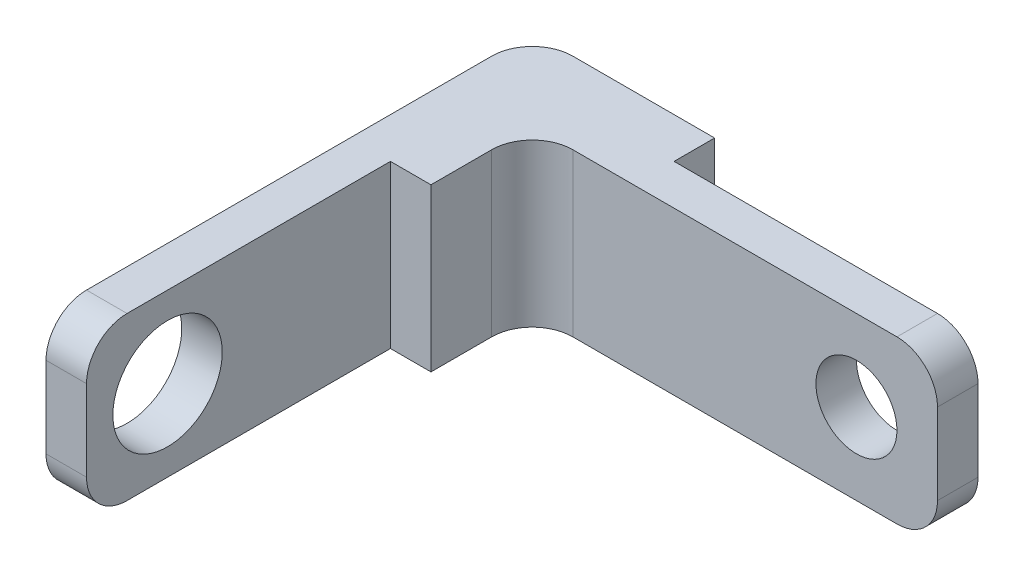
from build123d import *

# Parameters (mm, degrees)
SKETCH2_W           = 120
SKETCH2_H           = 40
BOSS_EXTRUDE1_DEPTH = 20
SKETCH3_W           = 20
SKETCH3_H           = 40
BOSS_EXTRUDE2_DEPTH = 100
SKETCH4_W           = 75
SKETCH4_H           = 40
CUT_EXTRUDE1_DEPTH  = 10
SKETCH5_W           = 75
SKETCH5_H           = 40
CUT_EXTRUDE2_DEPTH  = 10
CUT_EXTRUDE3_REACH  = 12
SKETCH6_R           = 13.5
FILLET2_R           = 10
SKETCH7_R           = 10
CUT_EXTRUDE4_DEPTH  = 10
FILLET3_R           = 10


with BuildPart() as part:
    # Sketch2 → Boss-Extrude1 (new body)
    with BuildSketch(Plane.XY):
        Rectangle(SKETCH2_W, SKETCH2_H)
    extrude(amount=BOSS_EXTRUDE1_DEPTH)

    # Sketch3 → Boss-Extrude2 (add)
    with BuildSketch(Plane.XY.offset(20)):
        with Locations((-50, 0)):
            Rectangle(SKETCH3_W, SKETCH3_H)
    extrude(amount=BOSS_EXTRUDE2_DEPTH)

    # Sketch4 → Cut-Extrude1 (cut)
    with BuildSketch(Plane(origin=(0, 0, 0), x_dir=(-1, 0, 0), z_dir=(0, 0, -1))):
        with Locations((-22.5, 0)):
            Rectangle(SKETCH4_W, SKETCH4_H)
    extrude(amount=-CUT_EXTRUDE1_DEPTH, mode=Mode.SUBTRACT)

    # Sketch5 → Cut-Extrude2 (cut)
    with BuildSketch(Plane(origin=(-40, 0, 0), x_dir=(0, 0, -1), z_dir=(1, 0, 0))):
        with Locations((-82.5, 0)):
            Rectangle(SKETCH5_W, SKETCH5_H)
    extrude(amount=-CUT_EXTRUDE2_DEPTH, mode=Mode.SUBTRACT)

    # Sketch6 → Cut-Extrude3 (cut, up to next)
    with BuildSketch(Plane(origin=(-50, 0, 0), x_dir=(0, 0, -1), z_dir=(1, 0, 0)), mode=Mode.PRIVATE) as cut_extrude3_sk1:
        with Locations((-100, 0)):
            Circle(SKETCH6_R)
    cut_extrude3_tool1 = extrude(cut_extrude3_sk1.sketch, amount=-CUT_EXTRUDE3_REACH, mode=Mode.PRIVATE) & part.part
    add(cut_extrude3_tool1.solids().sort_by_distance((-50, 0, 100))[0], mode=Mode.SUBTRACT)

    # Fillet2
    fillet2_edges = [part.edges().sort_by_distance(p)[0] for p in [
        (60, 20, 15),
        (60, -20, 15),
        (-55, -20, 120),
        (-55, 20, 120),
        (-60, 0, 0),
    ]]
    fillet(fillet2_edges, radius=FILLET2_R)

    # Sketch7 → Cut-Extrude4 (cut)
    with BuildSketch(Plane.XY.offset(20)):
        with Locations((40, 0)):
            Circle(SKETCH7_R)
    extrude(amount=-CUT_EXTRUDE4_DEPTH, mode=Mode.SUBTRACT)

    # Fillet3
    fillet3_edges = [part.edges().sort_by_distance(p)[0] for p in [
        (-40, 0, 20),
    ]]
    fillet(fillet3_edges, radius=FILLET3_R)


solid = part.part
